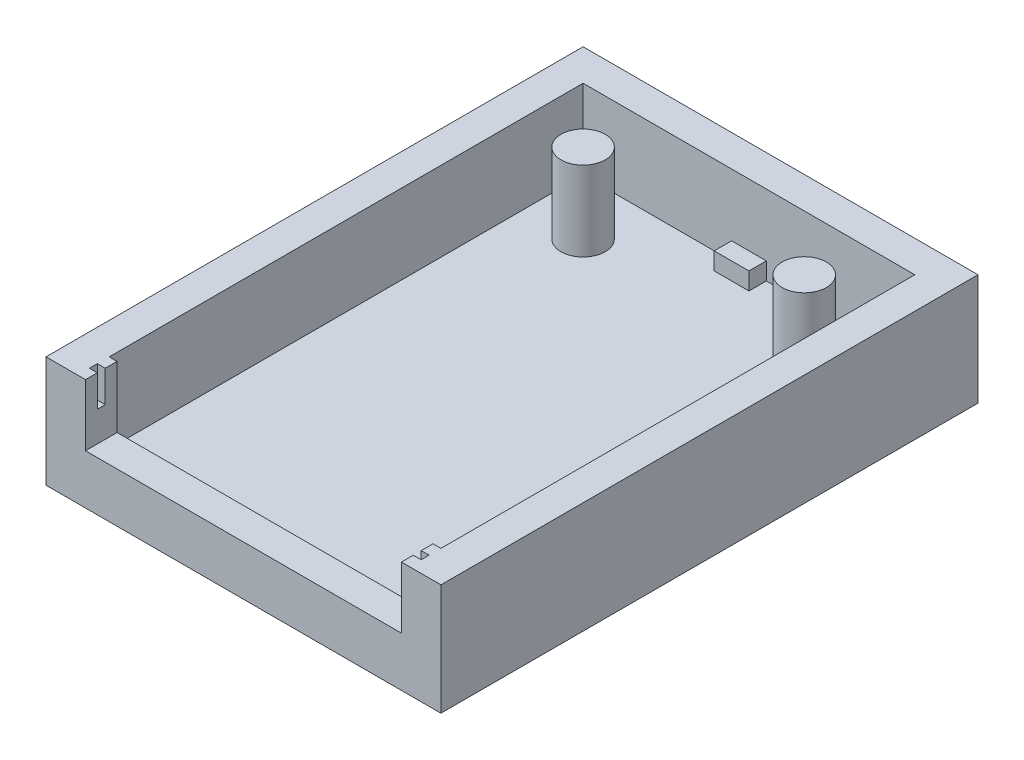
from build123d import *

# Parameters (mm, degrees)
IZIM1_W                     = 25
IZIM1_H                     = 34
Y_KSEKLIK_EKSTR_ZYON1_DEPTH = 7.04
IZIM2_W                     = 21
IZIM2_H                     = 30
IZIM2_R                     = 1.4
KES_EKSTR_ZYON1_DEPTH       = 5.04
IZIM3_W                     = 20
IZIM3_H                     = 5.688553579
KES_EKSTR_ZYON2_DEPTH       = 3.9
IZIM4_W                     = 2.2
IZIM4_H                     = 1.1
Y_KSEKLIK_EKSTR_ZYON2_DEPTH = 1.1
IZIM5_W                     = 1
IZIM5_H                     = 0.5
KES_EKSTR_ZYON3_DEPTH       = 2


with BuildPart() as part:
    # Çizim1 → Yükseklik-Ekstrüzyon1 (new body)
    with BuildSketch(Plane(origin=(0, 0, 0), x_dir=(1, 0, 0), z_dir=(0, 1, 0))):
        Rectangle(IZIM1_W, IZIM1_H)
    extrude(amount=Y_KSEKLIK_EKSTR_ZYON1_DEPTH)

    # Çizim2 → Kes-Ekstrüzyon1 (cut)
    with BuildSketch(Plane(origin=(0, 7.04, 0), x_dir=(1, 0, 0), z_dir=(0, 1, 0))):
        Rectangle(IZIM2_W, IZIM2_H)
        with Locations((-7, 11.5)):
            Circle(IZIM2_R, mode=Mode.SUBTRACT)
        with Locations((7, 11.5)):
            Circle(IZIM2_R, mode=Mode.SUBTRACT)
    extrude(amount=-KES_EKSTR_ZYON1_DEPTH, mode=Mode.SUBTRACT)

    # Çizim3 → Kes-Ekstrüzyon2 (cut)
    with BuildSketch(Plane(origin=(0, 7.04, 0), x_dir=(1, 0, 0), z_dir=(0, 1, 0))):
        with Locations((0, -14.80753211)):
            Rectangle(IZIM3_W, IZIM3_H)
    extrude(amount=-KES_EKSTR_ZYON2_DEPTH, mode=Mode.SUBTRACT)

    # Çizim4 → Yükseklik-Ekstrüzyon2 (add)
    with BuildSketch(Plane(origin=(0, 2, 0), x_dir=(1, 0, 0), z_dir=(0, 1, 0))):
        with Locations((0, 14.45)):
            Rectangle(IZIM4_W, IZIM4_H)
    extrude(amount=Y_KSEKLIK_EKSTR_ZYON2_DEPTH)

    # Çizim5 → Kes-Ekstrüzyon3 (cut)
    with BuildSketch(Plane(origin=(0, 7.04, 0), x_dir=(1, 0, 0), z_dir=(0, 1, 0))):
        with Locations((-10, -16)):
            Rectangle(IZIM5_W, IZIM5_H)
        with Locations((10, -16)):
            Rectangle(IZIM5_W, IZIM5_H)
    extrude(amount=-KES_EKSTR_ZYON3_DEPTH, mode=Mode.SUBTRACT)


solid = part.part
